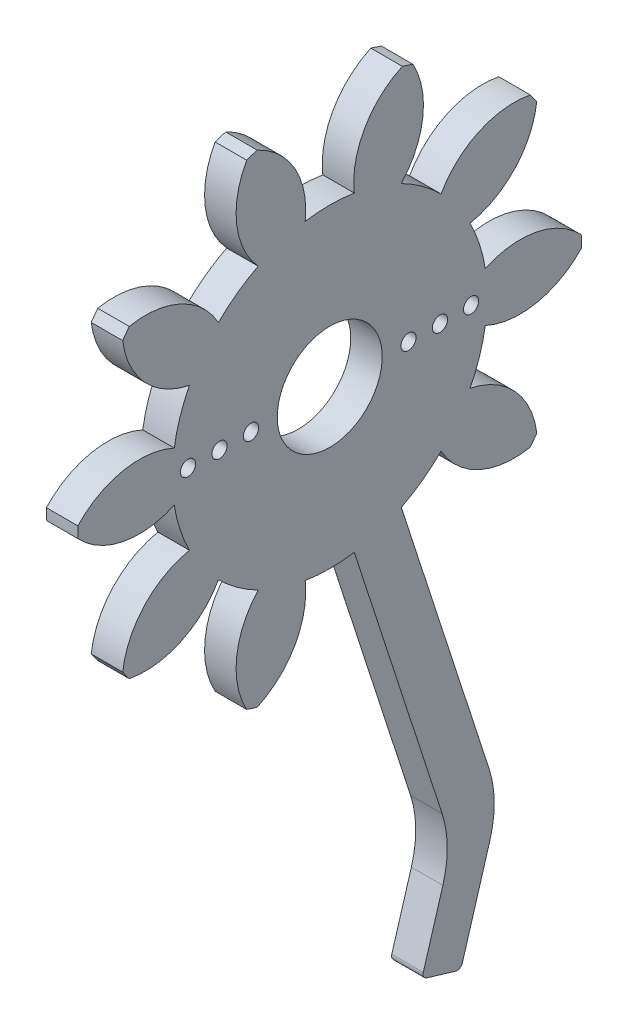
from build123d import *

# Parameters (mm, degrees)
BASPROSKE_W         = 3
BASPROSKE_H         = 24
TOOTHCUT_DEPTH      = 35.073450075
TEETHCUTS_COUNT     = 10
TEETHCUTS_ANGLE     = 324
BORSKE_R            = 5
BORE_DEPTH          = 50.0000508
CUT_EXTRUDE1_DEPTH  = 10
BOSS_EXTRUDE1_DEPTH = 3
FILLET1_R           = 10
FILLET2_R           = 0.5
SKETCH4_R           = 0.723099704
SKETCH4_R_2         = 0.723
CUT_EXTRUDE2_DEPTH  = 60.377084251


with BuildPart() as part:
    # BasProSke → Base-Revolve (revolve)
    with BuildSketch(Plane(origin=(0, 0, 0), x_dir=(1, 0, 0), z_dir=(0, 1, 0)), mode=Mode.PRIVATE) as base_revolve_sk:
        with Locations((1.5, 12)):
            Rectangle(BASPROSKE_W, BASPROSKE_H)
    revolve(base_revolve_sk.sketch.rotate(Axis((-10, 0, 0), (1, 0, 0)), 180), axis=Axis((-10, 0, 0), (1, 0, 0)))

    # TooCutSke → ToothCut (cut, through all)
    with BuildSketch(Plane(origin=(0, 0, 0), x_dir=(0, 0, -1), z_dir=(1, 0, 0))):
        with BuildLine():
            ThreePointArc((2.33803632, 14.815653451), (0, 14.999), (-2.33803632, 14.815653451))
            ThreePointArc((-2.33803632, 14.815653451), (-3.315013319, 19.654913653), (-6.946609122, 22.999227528))
            ThreePointArc((-6.946609122, 22.999227528), (0, 24.0254), (6.946609122, 22.999227528))
            ThreePointArc((6.946609122, 22.999227528), (3.315013319, 19.654913653), (2.33803632, 14.815653451))
        make_face()
    toothcut = extrude(amount=TOOTHCUT_DEPTH, mode=Mode.SUBTRACT)

    # TeethCuts: ToothCut ×10 about axis
    teethcuts_axis = Axis((-10, 0, 0), (1, 0, 0))
    for i in range(1, TEETHCUTS_COUNT):
        add(toothcut.rotate(teethcuts_axis, i * TEETHCUTS_ANGLE / (TEETHCUTS_COUNT - 1)), mode=Mode.SUBTRACT)

    # BorSke → Bore (cut, symmetric)
    with BuildSketch(Plane(origin=(0, 0, 0), x_dir=(0, 0, -1), z_dir=(1, 0, 0))):
        with Locations(Location((0, 0, 0), (0, 0, 180))):
            Circle(BORSKE_R)
    extrude(amount=BORE_DEPTH, both=True, mode=Mode.SUBTRACT)

    # Sketch2 → Cut-Extrude1 (cut)
    with BuildSketch(Plane(origin=(3, 0, 0), x_dir=(0, 0, -1), z_dir=(1, 0, 0))):
        Polygon((6.816911485, -13.360378693), (2.33803632, -14.815653451), (-0.141133304, -15.621184492), (3.422057866, -26.587559293), (12.21539263, -23.730431632), (8.652201461, -12.764056831), align=None)
    extrude(amount=-CUT_EXTRUDE1_DEPTH, mode=Mode.SUBTRACT)

    # Sketch3 → Boss-Extrude1 (add)
    with BuildSketch(Plane(origin=(3, 0, 0), x_dir=(0, 0, -1), z_dir=(1, 0, 0))):
        Polygon((16.145202329, -42.069905854), (12.47904632, -54.349791311), (8.765627157, -53.241151167), (11.666327165, -43.525180612), align=None)
        Polygon((11.666327165, -43.525180612), (16.145202329, -42.069905854), (6.816911485, -13.360378693), (2.33803632, -14.815653451), align=None)
    extrude(amount=-BOSS_EXTRUDE1_DEPTH)

    # Fillet1
    fillet1_edges = [part.edges().sort_by_distance(p)[0] for p in [
        (1.5, -42.069905854, -16.145202329),
        (1.5, -43.525180612, -11.666327165),
    ]]
    fillet(fillet1_edges, radius=FILLET1_R)

    # Fillet2
    fillet2_edges = [part.edges().sort_by_distance(p)[0] for p in [
        (1.5, -54.349791311, -12.47904632),
        (1.5, -53.241151167, -8.765627157),
    ]]
    fillet(fillet2_edges, radius=FILLET2_R)

    # Sketch4 → Cut-Extrude2 (cut, through all)
    with BuildSketch(Plane.ZY):
        with Locations((7.499935211, 0.031174107)):
            Circle(SKETCH4_R)
        with Locations((10.499909296, 0.04364375)):
            Circle(SKETCH4_R_2)
        with Locations((13.499883381, 0.056113393)):
            Circle(SKETCH4_R_2)
        with Locations((-7.499935211, -0.031174107)):
            Circle(SKETCH4_R_2)
        with Locations((-10.499909296, -0.04364375)):
            Circle(SKETCH4_R_2)
        with Locations((-13.462606147, 0)):
            Circle(SKETCH4_R_2)
    extrude(amount=-CUT_EXTRUDE2_DEPTH, mode=Mode.SUBTRACT)


solid = part.part
